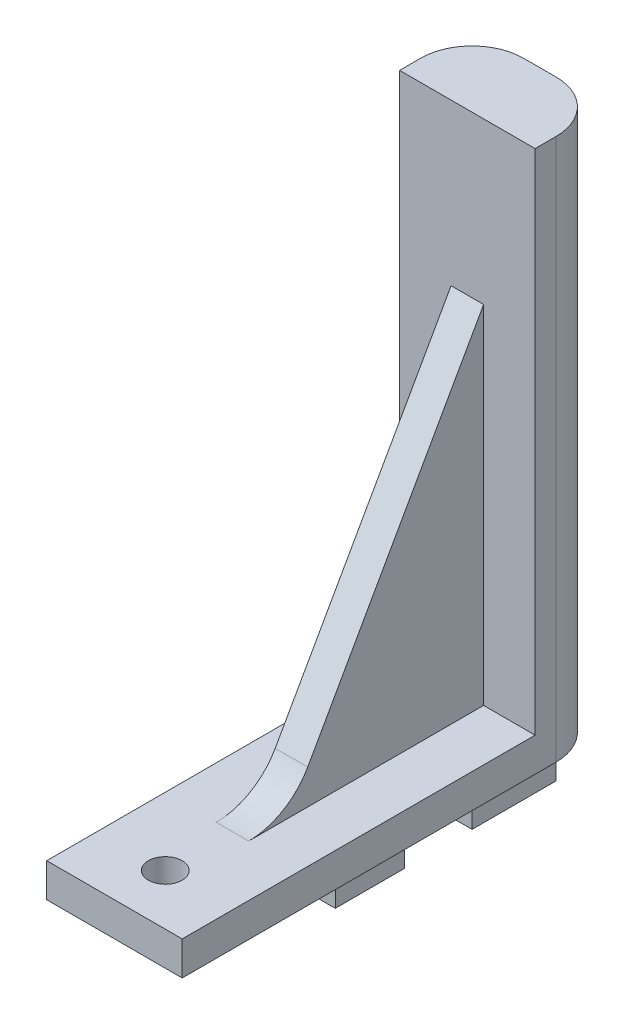
from build123d import *

# Parameters (mm, degrees)
BOSS_EXTRUDE1_DEPTH = 6.35
SKETCH1_3_W         = 6.477
SKETCH1_3_H         = 6.35
BOSS_EXTRUDE2_DEPTH = 1.524
SKETCH2_R           = 1.5875
CUT_EXTRUDE1_DEPTH  = 51.8
FILLET1_R           = 4.826
FILLET2_R           = 6.35
SKETCH4_W           = 4.826
SKETCH4_H           = 33.0835
CUT_EXTRUDE5_DEPTH  = 47.625


with BuildPart() as part:
    # Sketch1 → Boss-Extrude1 (new body, symmetric)
    with BuildSketch(Plane(origin=(0, 0, 0), x_dir=(0, 0, -1), z_dir=(1, 0, 0))):
        Polygon((-19.939, 3.175), (-19.939, 0), (19.939, 0), (19.939, 50.8), (13.1445, 50.8), (13.1445, 35.729333418), (-5.167312548, 3.175), align=None)
    extrude(amount=BOSS_EXTRUDE1_DEPTH, both=True)

    # Sketch1_3 → Boss-Extrude2 (add, symmetric)
    with BuildSketch(Plane(origin=(0, 0, 0), x_dir=(0, 0, -1), z_dir=(1, 0, 0))):
        Polygon((13.1445, 0), (12.065, 0), (12.065, -6.35), (19.939, -6.35), (19.939, 0), align=None)
        with Locations((2.4765, -3.175)):
            Rectangle(SKETCH1_3_W, SKETCH1_3_H)
    extrude(amount=BOSS_EXTRUDE2_DEPTH, both=True)

    # Sketch2 → Cut-Extrude1 (cut, through all)
    with BuildSketch(Plane.XZ):
        with Locations((0, 15.1765)):
            Circle(SKETCH2_R)
    extrude(amount=-CUT_EXTRUDE1_DEPTH, mode=Mode.SUBTRACT)

    # Fillet1
    fillet1_edges = [part.edges().sort_by_distance(p)[0] for p in [
        (-6.35, 25.4, -19.939),
        (6.35, 25.4, -19.939),
    ]]
    fillet(fillet1_edges, radius=FILLET1_R)

    # Fillet2
    fillet2_edges = [part.edges().sort_by_distance(p)[0] for p in [
        (0, 3.175, 5.167312548),
    ]]
    fillet(fillet2_edges, radius=FILLET2_R)

    # Sketch4 → Cut-Extrude5 (cut)
    with BuildSketch(Plane(origin=(0, 50.8, 0), x_dir=(1, 0, 0), z_dir=(0, 1, 0))):
        with Locations((-3.937, -3.39725)):
            Rectangle(SKETCH4_W, SKETCH4_H)
        with Locations((3.937, -3.39725)):
            Rectangle(SKETCH4_W, SKETCH4_H)
    extrude(amount=-CUT_EXTRUDE5_DEPTH, mode=Mode.SUBTRACT)


solid = part.part
